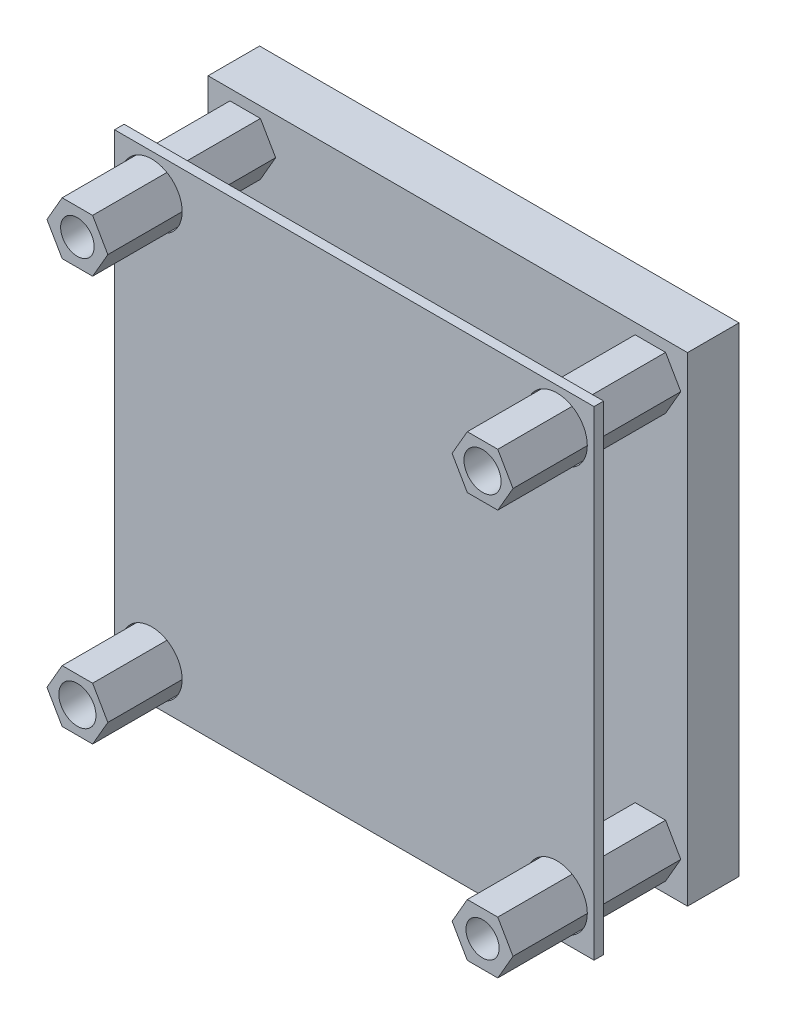
from build123d import *

# Parameters (mm, degrees)
SKETCH1_W             = 40
SKETCH1_H             = 40
BOSS_EXTRUDE1_DEPTH   = 4.3
SKETCH2_R             = 1.4
BOSS_EXTRUDE2_DEPTH   = 14
SKETCH2_R_2           = 1.55
BOSS_EXTRUDE2_2_DEPTH = 14
BOSS_EXTRUDE2_3_DEPTH = 14
SKETCH2_R_3           = 1.383952534
BOSS_EXTRUDE2_4_DEPTH = 14
SKETCH4_W             = 40
SKETCH4_H             = 40
SKETCH4_R             = 2.540341184
BOSS_EXTRUDE3_DEPTH   = 0.8


with BuildPart() as part:
    # Sketch1 → Boss-Extrude1 (new body)
    with BuildSketch(Plane.XY):
        Rectangle(SKETCH1_W, SKETCH1_H)
    extrude(amount=BOSS_EXTRUDE1_DEPTH)


with BuildPart() as body_2:
    # Sketch2 → Boss-Extrude2 (new body)
    with BuildSketch(Plane.XY.offset(4.3)):
        Polygon((-14.359658816, 16.9), (-15.629829408, 19.1), (-18.170170592, 19.1), (-19.440341184, 16.9), (-18.170170592, 14.7), (-15.629829408, 14.7), align=None)
        with Locations((-16.9, 16.9)):
            Circle(SKETCH2_R, mode=Mode.SUBTRACT)
    extrude(amount=BOSS_EXTRUDE2_DEPTH)


with BuildPart() as body_3:
    # Sketch2 → Boss-Extrude2 2 (new body)
    with BuildSketch(Plane.XY.offset(4.3)):
        Polygon((14.359658816, 16.9), (15.629829408, 14.7), (18.170170592, 14.7), (19.440341184, 16.9), (18.170170592, 19.1), (15.629829408, 19.1), align=None)
        with Locations((16.9, 16.9)):
            Circle(SKETCH2_R_2, mode=Mode.SUBTRACT)
    extrude(amount=BOSS_EXTRUDE2_2_DEPTH)


with BuildPart() as body_4:
    # Sketch2 → Boss-Extrude2 3 (new body)
    with BuildSketch(Plane.XY.offset(4.3)):
        Polygon((-14.359658816, -16.9), (-15.629829408, -14.7), (-18.170170592, -14.7), (-19.440341184, -16.9), (-18.170170592, -19.1), (-15.629829408, -19.1), align=None)
        with Locations((-16.9, -16.9)):
            Circle(SKETCH2_R_2, mode=Mode.SUBTRACT)
    extrude(amount=BOSS_EXTRUDE2_3_DEPTH)


with BuildPart() as body_5:
    # Sketch2 → Boss-Extrude2 4 (new body)
    with BuildSketch(Plane.XY.offset(4.3)):
        Polygon((19.440341184, -16.9), (18.170170592, -14.7), (15.629829408, -14.7), (14.359658816, -16.9), (15.629829408, -19.1), (18.170170592, -19.1), align=None)
        with Locations((16.9, -16.9)):
            Circle(SKETCH2_R_3, mode=Mode.SUBTRACT)
    extrude(amount=BOSS_EXTRUDE2_4_DEPTH)


with BuildPart() as body_6:
    # Sketch4 → Boss-Extrude3 (new body)
    with BuildSketch(Plane.XY.offset(11.3)):
        Rectangle(SKETCH4_W, SKETCH4_H)
        with Locations((-16.9, 16.9)):
            Circle(SKETCH4_R, mode=Mode.SUBTRACT)
        with Locations((16.9, 16.9)):
            Circle(SKETCH4_R, mode=Mode.SUBTRACT)
        with Locations((16.9, -16.9)):
            Circle(SKETCH4_R, mode=Mode.SUBTRACT)
        with Locations((-16.9, -16.9)):
            Circle(SKETCH4_R, mode=Mode.SUBTRACT)
    extrude(amount=BOSS_EXTRUDE3_DEPTH)


solid = Compound([part.part, body_2.part, body_3.part, body_4.part, body_5.part, body_6.part])
